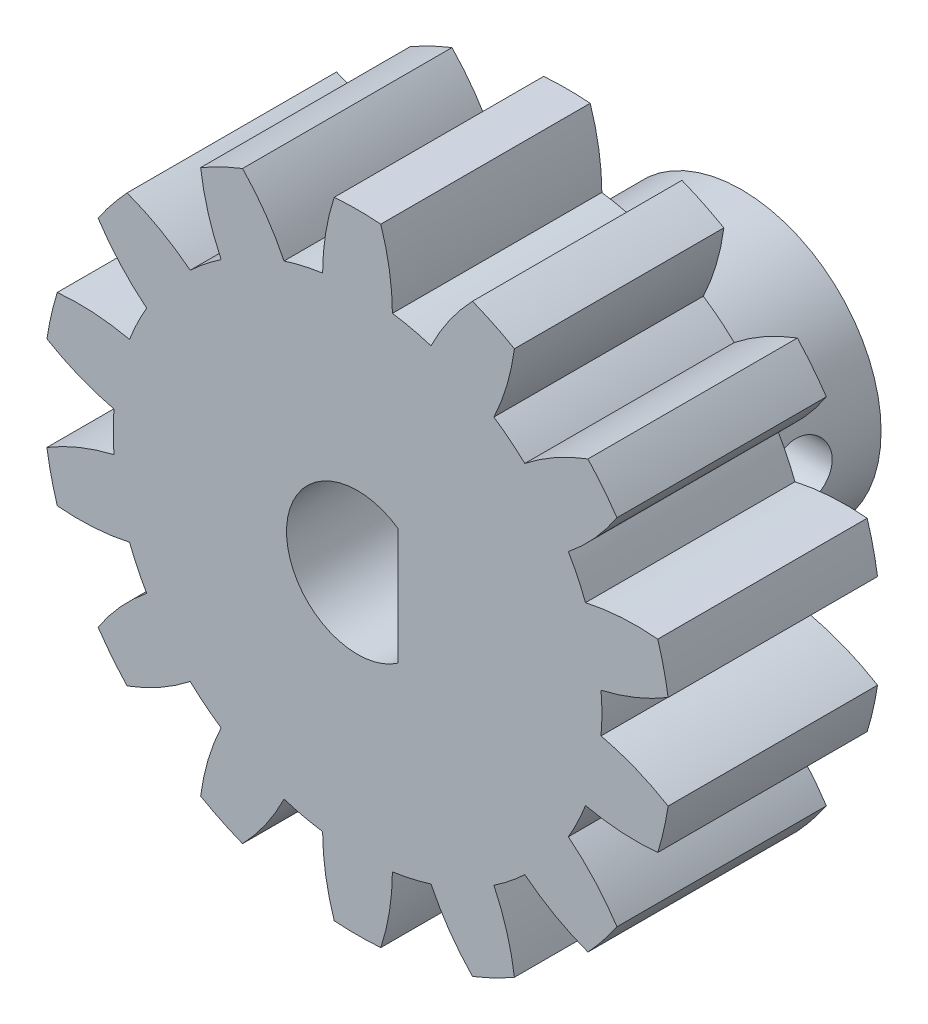
from build123d import *

# Parameters (mm, degrees)
SKETCH1_R               = 6
SKETCH1_R_2             = 3.05
BOSS_EXTRUDE1_DEPTH     = 7.5
SKETCH2_R               = 10.5
BOSS_EXTRUDE3_DEPTH     = 9
BOSS_EXTRUDE4_DEPTH     = 9
CIRPATTERN1_COUNT       = 14
SKETCH3_R               = 3.05
CUT_EXTRUDE1_DEPTH      = 10
SKETCH5_W               = 1.3
SKETCH5_H               = 8.98796618
BOSS_EXTRUDE5_DEPTH     = 16.5
SKETCH4_R               = 1.4
CUT_EXTRUDE2_DEPTH      = 1
CUT_EXTRUDE2_DEPTH_BACK = 38.540546983


with BuildPart() as part:
    # Sketch1 → Boss-Extrude1 (new body)
    with BuildSketch(Plane.XY):
        with Locations((-24.192657344, -27.82930415)):
            Circle(SKETCH1_R)
        with Locations((-24.192657344, -27.82930415)):
            Circle(SKETCH1_R_2, mode=Mode.SUBTRACT)
    extrude(amount=BOSS_EXTRUDE1_DEPTH)

    # Sketch2 → Boss-Extrude3 (add)
    with BuildSketch(Plane.XY.offset(7.5)):
        with Locations((-24.192657344, -27.82930415)):
            Circle(SKETCH2_R)
    extrude(amount=BOSS_EXTRUDE3_DEPTH)

    # Sketch2_4 → Boss-Extrude4 (add)
    with BuildSketch(Plane.XY.offset(7.5)):
        with BuildLine():
            ThreePointArc((-22.692657344, -17.436999304), (-22.822516009, -15.882132595), (-23.192657344, -14.366392132))
            ThreePointArc((-23.192657344, -14.366392132), (-24.192657344, -14.32930415), (-25.192657344, -14.366392132))
            ThreePointArc((-25.192657344, -14.366392132), (-25.562798679, -15.882132595), (-25.692657344, -17.436999304))
            ThreePointArc((-25.692657344, -17.436999304), (-24.192657344, -17.32930415), (-22.692657344, -17.436999304))
        make_face()
    boss_extrude4 = extrude(amount=BOSS_EXTRUDE4_DEPTH)

    # CirPattern1: Boss-Extrude4 ×14 about axis
    cirpattern1_axis = Axis((-24.192657344, -27.82930415, 0), (0, 0, 1))
    for i in range(1, CIRPATTERN1_COUNT):
        add(boss_extrude4.rotate(cirpattern1_axis, i * 360 / CIRPATTERN1_COUNT))

    # Sketch3 → Cut-Extrude1 (cut, through all)
    with BuildSketch(Plane(origin=(0, 0, 7.5), x_dir=(-1, 0, 0), z_dir=(0, 0, -1))):
        with Locations((24.192657344, -27.82930415)):
            Circle(SKETCH3_R)
    extrude(amount=-CUT_EXTRUDE1_DEPTH, mode=Mode.SUBTRACT)

    # Sketch5 → Boss-Extrude5 (add, through all)
    with BuildSketch(Plane(origin=(0, 0, 0), x_dir=(-1, 0, 0), z_dir=(0, 0, -1))):
        with Locations((21.792657344, -27.156324883)):
            Rectangle(SKETCH5_W, SKETCH5_H)
    extrude(amount=-BOSS_EXTRUDE5_DEPTH)

    # Sketch4 → Cut-Extrude2 (cut, two sides)
    with BuildSketch(Plane(origin=(0, 0, 0), x_dir=(0, 0, -1), z_dir=(1, 0, 0))) as cut_extrude2_sk:
        with Locations((-3.5, -27.82930415)):
            Circle(SKETCH4_R)
    extrude(amount=CUT_EXTRUDE2_DEPTH, mode=Mode.SUBTRACT)
    extrude(cut_extrude2_sk.sketch, amount=-CUT_EXTRUDE2_DEPTH_BACK, mode=Mode.SUBTRACT)


solid = part.part
